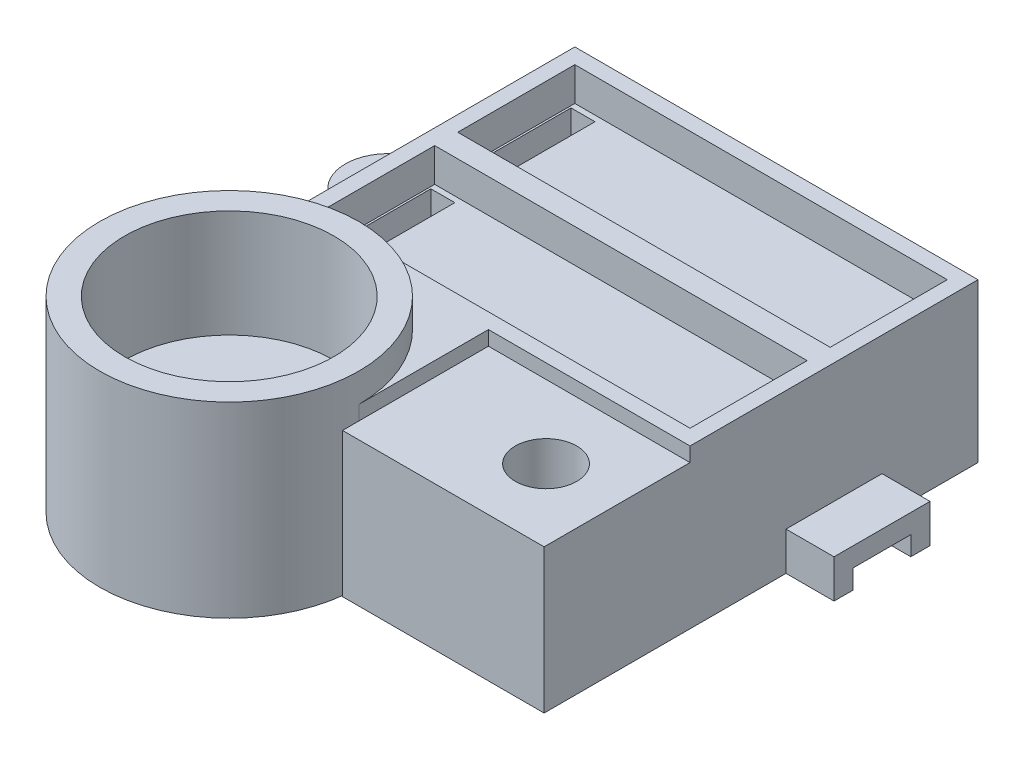
from build123d import *
from build123d.topology import SkipClean

# Parameters (mm, degrees)
SKETCH1_W            = 42
SKETCH1_H            = 30
BOSS_EXTRUDE1_DEPTH  = 10.5
SKETCH2_W            = 38.8
SKETCH2_H            = 12.2
CUT_EXTRUDE1_DEPTH   = 3.5
SKETCH3_W            = 2.5
SKETCH3_H            = 11
CUT_EXTRUDE2_DEPTH   = 2.6
SKETCH4_R            = 0.75
CUT_EXTRUDE3_DEPTH   = 52.973166153
SKETCH13_R           = 1.45
SKETCH13_W           = 1.6
SKETCH13_H           = 6.1
BOSS_EXTRUDE6_DEPTH  = 6
SKETCH15_R           = 4.45
SKETCH15_R_2         = 1.5
BOSS_EXTRUDE7_DEPTH  = 6
BOSS_EXTRUDE8_START  = 3
SKETCH16_R           = 1.5
BOSS_EXTRUDE8_DEPTH  = 3
SKETCH17_W           = 21
SKETCH17_H           = 10.5
BOSS_EXTRUDE9_DEPTH  = 21
BOSS_EXTRUDE20_DEPTH = 27
CUT_EXTRUDE15_DEPTH  = 27
SKETCH45_R           = 10.9
CUT_EXTRUDE16_DEPTH  = 8.2
CUT_EXTRUDE17_DEPTH  = 53.836445755
SKETCH48_W           = 3
SKETCH48_H           = 3
CUT_EXTRUDE18_DEPTH  = 15.1
SKETCH49_R           = 13.5
SKETCH49_R_2         = 10.9
BOSS_EXTRUDE21_DEPTH = 3
SKETCH51_W           = 28.827310349
SKETCH51_H           = 3
CUT_EXTRUDE20_DEPTH  = 54.350257731
SKETCH52_W           = 6
SKETCH52_H           = 2
CUT_EXTRUDE21_DEPTH  = 10
BOSS_EXTRUDE22_DEPTH = 5
SKETCH54_R           = 1.5
CUT_EXTRUDE22_DEPTH  = 3
SKETCH55_R           = 1.5
SKETCH55_R_2         = 1.45
BOSS_EXTRUDE23_DEPTH = 3
SKETCH57_W           = 21
SKETCH57_H           = 21
BOSS_EXTRUDE25_DEPTH = 3
SKETCH58_W           = 21
SKETCH58_H           = 5.8
CUT_EXTRUDE23_DEPTH  = 58.36941694
SKETCH59_R           = 3.2
CUT_EXTRUDE24_DEPTH  = 150
SKETCH60_W           = 21
SKETCH60_H           = 15.2
SKETCH60_R           = 3.2
BOSS_EXTRUDE26_DEPTH = 1.5
CUT_EXTRUDE25_DEPTH  = 3


with BuildPart() as part:
    # Sketch1 → Boss-Extrude1 (new body)
    with BuildSketch(Plane(origin=(0, 0, 0), x_dir=(1, 0, 0), z_dir=(0, 1, 0))):
        with Locations((21, 15)):
            Rectangle(SKETCH1_W, SKETCH1_H)
    extrude(amount=BOSS_EXTRUDE1_DEPTH)

    # Sketch2 → Cut-Extrude1 (cut)
    with BuildSketch(Plane(origin=(0, 10.5, 0), x_dir=(1, 0, 0), z_dir=(0, 1, 0))):
        with Locations((21, 22.3)):
            Rectangle(SKETCH2_W, SKETCH2_H)
        with Locations((21, 7.7)):
            Rectangle(SKETCH2_W, SKETCH2_H)
    extrude(amount=-CUT_EXTRUDE1_DEPTH, mode=Mode.SUBTRACT)

    # Sketch3 → Cut-Extrude2 (cut)
    with BuildSketch(Plane(origin=(0, 7, 0), x_dir=(1, 0, 0), z_dir=(0, 1, 0))):
        with Locations((3.05, 22.3)):
            Rectangle(SKETCH3_W, SKETCH3_H)
        with Locations((3.05, 7.7)):
            Rectangle(SKETCH3_W, SKETCH3_H)
    extrude(amount=-CUT_EXTRUDE2_DEPTH, mode=Mode.SUBTRACT)

    # Sketch4 → Cut-Extrude3 (cut, through all)
    with BuildSketch(Plane(origin=(0, 4.4, 0), x_dir=(1, 0, 0), z_dir=(0, 1, 0))):
        with Locations((3.05, 26.05)):
            Circle(SKETCH4_R)
        with BuildLine():
            ThreePointArc((3.8, 26.05), (3.05, 25.3), (2.3, 26.05))
            Line((2.3, 26.05), (2.3, 23.8))
            ThreePointArc((2.3, 23.8), (3.05, 24.55), (3.8, 23.8))
            Line((3.8, 23.8), (3.8, 26.05))
        make_face()
        with Locations((3.05, 23.8)):
            Circle(SKETCH4_R)
        with BuildLine():
            ThreePointArc((3.8, 23.8), (3.05, 23.05), (2.3, 23.8))
            Line((2.3, 23.8), (2.3, 20.8))
            ThreePointArc((2.3, 20.8), (3.05, 21.55), (3.8, 20.8))
            Line((3.8, 20.8), (3.8, 23.8))
        make_face()
        with Locations((3.05, 20.8)):
            Circle(SKETCH4_R)
        with BuildLine():
            ThreePointArc((3.8, 20.8), (3.05, 20.05), (2.3, 20.8))
            Line((2.3, 20.8), (2.3, 18.55))
            ThreePointArc((2.3, 18.55), (3.05, 19.3), (3.8, 18.55))
            Line((3.8, 18.55), (3.8, 20.8))
        make_face()
        with Locations((3.05, 18.55)):
            Circle(SKETCH4_R)
        with Locations((3.05, 11.45)):
            Circle(SKETCH4_R)
        with BuildLine():
            ThreePointArc((3.8, 11.45), (3.05, 10.7), (2.3, 11.45))
            Line((2.3, 11.45), (2.3, 9.2))
            ThreePointArc((2.3, 9.2), (3.05, 9.95), (3.8, 9.2))
            Line((3.8, 9.2), (3.8, 11.45))
        make_face()
        with Locations((3.05, 9.2)):
            Circle(SKETCH4_R)
        with BuildLine():
            ThreePointArc((3.8, 9.2), (3.05, 8.45), (2.3, 9.2))
            Line((2.3, 9.2), (2.3, 6.2))
            ThreePointArc((2.3, 6.2), (3.05, 6.95), (3.8, 6.2))
            Line((3.8, 6.2), (3.8, 9.2))
        make_face()
        with Locations((3.05, 6.2)):
            Circle(SKETCH4_R)
        with BuildLine():
            ThreePointArc((3.8, 6.2), (3.05, 5.45), (2.3, 6.2))
            Line((2.3, 6.2), (2.3, 3.95))
            ThreePointArc((2.3, 3.95), (3.05, 4.7), (3.8, 3.95))
            Line((3.8, 3.95), (3.8, 6.2))
        make_face()
        with Locations((3.05, 3.95)):
            Circle(SKETCH4_R)
    extrude(amount=-CUT_EXTRUDE3_DEPTH, mode=Mode.SUBTRACT)

    # Sketch13 → Boss-Extrude6 (add)
    # profile 1 of 12: a face of its own
    with BuildSketch(Plane.XZ):
        with BuildLine():
            Line((40.4, -28.4), (40.4, -22.132398502))
            ThreePointArc((40.4, -22.132398502), (39.065614287, -21.3660529), (37.55, -21.1))
            ThreePointArc((37.55, -21.1), (33.519801494, -23.663203774), (34.132398502, -28.4))
            Line((34.132398502, -28.4), (40.4, -28.4))
        make_face()
        with Locations(Location((37.55, -25.55, 0), (0, 0, 270))):
            Circle(SKETCH13_R, mode=Mode.SUBTRACT)
    # profile 2 of 12: a face of its own
    with BuildSketch(Plane.XZ):
        with BuildLine():
            ThreePointArc((37.55, -30), (40.696625176, -28.696625176), (42, -25.55))
            ThreePointArc((42, -25.55), (41.580198506, -23.663203774), (40.4, -22.132398502))
            Line((40.4, -22.132398502), (40.4, -28.4))
            Line((40.4, -28.4), (34.132398502, -28.4))
            ThreePointArc((34.132398502, -28.4), (35.663203774, -29.580198506), (37.55, -30))
        make_face()
    # profile 3 of 12: a face of its own
    with BuildSketch(Plane.XZ):
        with BuildLine():
            Line((42, -30), (42, -25.55))
            ThreePointArc((42, -25.55), (40.696625176, -28.696625176), (37.55, -30))
            Line((37.55, -30), (42, -30))
        make_face()
    # profile 4 of 12: a face of its own
    with BuildSketch(Plane.XZ):
        with BuildLine():
            Line((1.6, -15), (0, -15))
            Line((0, -15), (0, -30))
            Line((0, -30), (37.55, -30))
            ThreePointArc((37.55, -30), (35.663203774, -29.580198506), (34.132398502, -28.4))
            Line((34.132398502, -28.4), (1.6, -28.4))
            Line((1.6, -28.4), (1.6, -15))
        make_face()
    # profile 5 of 12: a face of its own
    with BuildSketch(Plane.XZ):
        with BuildLine():
            ThreePointArc((37.55, -8.9), (39.065614287, -8.6339471), (40.4, -7.867601498))
            Line((40.4, -7.867601498), (40.4, -1.6))
            Line((40.4, -1.6), (34.132398502, -1.6))
            ThreePointArc((34.132398502, -1.6), (33.519801494, -6.336796226), (37.55, -8.9))
        make_face()
        with Locations(Location((37.55, -4.45, 0), (0, 0, 270))):
            Circle(SKETCH13_R, mode=Mode.SUBTRACT)
    # profile 6 of 12: a face of its own
    with BuildSketch(Plane.XZ):
        with BuildLine():
            ThreePointArc((40.4, -7.867601498), (41.580198506, -6.336796226), (42, -4.45))
            ThreePointArc((42, -4.45), (40.696625172, -1.30337482), (37.549999989, 0))
            ThreePointArc((37.549999989, 0), (35.663203769, -0.419801496), (34.132398502, -1.6))
            Line((34.132398502, -1.6), (40.4, -1.6))
            Line((40.4, -1.6), (40.4, -7.867601498))
        make_face()
    # profile 7 of 12: a face of its own
    with BuildSketch(Plane.XZ):
        with BuildLine():
            Line((42, -4.45), (42, 0))
            Line((42, 0), (37.549999989, 0))
            ThreePointArc((37.549999989, 0), (40.696625172, -1.30337482), (42, -4.45))
        make_face()
    # profile 8 of 12: a face of its own
    with BuildSketch(Plane.XZ):
        with BuildLine():
            ThreePointArc((34.132398502, -1.6), (35.663203769, -0.419801496), (37.549999989, 0))
            Line((37.549999989, 0), (0, 0))
            Line((0, 0), (0, -15))
            Line((0, -15), (1.6, -15))
            Line((1.6, -15), (1.6, -1.6))
            Line((1.6, -1.6), (34.132398502, -1.6))
        make_face()
    # profile 9 of 12: a face of its own
    with BuildSketch(Plane.XZ):
        with BuildLine():
            Line((42, -8.9), (42, -4.45))
            ThreePointArc((42, -4.45), (41.580198506, -6.336796226), (40.4, -7.867601498))
            Line((40.4, -7.867601498), (40.4, -8.9))
            Line((40.4, -8.9), (42, -8.9))
        make_face()
    # profile 10 of 12: a face of its own
    with BuildSketch(Plane.XZ):
        with BuildLine():
            Line((42, -25.55), (42, -21.1))
            Line((42, -21.1), (40.4, -21.1))
            Line((40.4, -21.1), (40.4, -22.132398502))
            ThreePointArc((40.4, -22.132398502), (41.580198506, -23.663203774), (42, -25.55))
        make_face()
    # profile 11 of 12: a face of its own
    with BuildSketch(Plane.XZ):
        with Locations((41.2, -18.05)):
            Rectangle(SKETCH13_W, SKETCH13_H)
    # profile 12 of 12: a face of its own
    with BuildSketch(Plane.XZ):
        with Locations((41.2, -11.95)):
            Rectangle(SKETCH13_W, SKETCH13_H)
    extrude(amount=BOSS_EXTRUDE6_DEPTH)

    # Sketch15 → Boss-Extrude7 (add)
    # profile 1 of 3: a face of its own
    with BuildSketch(Plane.XZ):
        with Locations((-4.45, -15)):
            Circle(SKETCH15_R)
        with Locations(Location((-4.45, -15, 0), (0, 0, 270))):
            Circle(SKETCH15_R_2, mode=Mode.SUBTRACT)
    # profile 2 of 3: a face of its own
    with BuildSketch(Plane.XZ):
        with BuildLine():
            Line((0, -10.55), (-4.45, -10.55))
            ThreePointArc((-4.45, -10.55), (-1.303374824, -11.853374824), (0, -15))
            Line((0, -15), (0, -10.55))
        make_face()
    # profile 3 of 3: a face of its own
    with BuildSketch(Plane.XZ):
        with BuildLine():
            Line((0, -19.45), (0, -15))
            ThreePointArc((0, -15), (-1.303374824, -18.146625176), (-4.45, -19.45))
            Line((-4.45, -19.45), (0, -19.45))
        make_face()
    extrude(amount=BOSS_EXTRUDE7_DEPTH)

    # Sketch16 → Boss-Extrude8 (add)
    # profile 1 of 4: a face of its own
    with BuildSketch(Plane(origin=(0, 0, 0), x_dir=(1, 0, 0), z_dir=(0, 1, 0)).offset(BOSS_EXTRUDE8_START)):
        with BuildLine():
            Line((0, 19.45), (-4.45, 19.45))
            ThreePointArc((-4.45, 19.45), (-1.303374824, 18.146625176), (0, 15))
            Line((0, 15), (0, 19.45))
        make_face()
    # profile 2 of 4: a face of its own
    with BuildSketch(Plane(origin=(0, 0, 0), x_dir=(1, 0, 0), z_dir=(0, 1, 0)).offset(BOSS_EXTRUDE8_START)):
        with BuildLine():
            Line((0, 10.55), (0, 15))
            ThreePointArc((0, 15), (-1.303374824, 11.853374824), (-4.45, 10.55))
            Line((-4.45, 10.55), (0, 10.55))
        make_face()
    # profile 3 of 4: a face of its own
    with BuildSketch(Plane(origin=(0, 0, 0), x_dir=(1, 0, 0), z_dir=(0, 1, 0)).offset(BOSS_EXTRUDE8_START)):
        with BuildLine():
            ThreePointArc((0, 15), (-1.303374824, 18.146625176), (-4.45, 19.45))
            ThreePointArc((-4.45, 19.45), (-8.9, 15), (-4.45, 10.55))
            ThreePointArc((-4.45, 10.55), (-1.303374824, 11.853374824), (0, 15))
        make_face()
        with Locations(Location((-4.45, 15, 0), (0, 0, 90))):
            Circle(SKETCH16_R, mode=Mode.SUBTRACT)
    # profile 4 of 4: a face of its own
    with BuildSketch(Plane(origin=(0, 0, 0), x_dir=(1, 0, 0), z_dir=(0, 1, 0)).offset(BOSS_EXTRUDE8_START)):
        with Locations(Location((-4.45, 15, 0), (0, 0, 90))):
            Circle(SKETCH16_R)
    extrude(amount=-BOSS_EXTRUDE8_DEPTH)

    # Sketch43 → Boss-Extrude20 (add)
    with BuildSketch(Plane.XY):
        Polygon((21, 10.5), (21, -6), (21, -9), (-6, -9), (-6, -6), (-6, 10.5), align=None)
    extrude(amount=BOSS_EXTRUDE20_DEPTH)

    # Sketch44 → Cut-Extrude15 (cut)
    with BuildSketch(Plane(origin=(0, 10.5, 0), x_dir=(1, 0, 0), z_dir=(0, 1, 0))):
        with BuildLine():
            ThreePointArc((21, -13.5), (17.045941546, -23.045941546), (7.5, -27))
            Line((7.5, -27), (21, -27))
            Line((21, -27), (21, -13.5))
        make_face()
        with BuildLine():
            ThreePointArc((7.5, -27), (-2.045941546, -23.045941546), (-6, -13.5))
            Line((-6, -13.5), (-6, -27))
            Line((-6, -27), (7.5, -27))
        make_face()
        with BuildLine():
            Line((-6, 0), (-6, -13.5))
            ThreePointArc((-6, -13.5), (-4.4058809, -7.136038969), (0, -2.27502784))
            Line((0, -2.27502784), (0, 0))
            Line((0, 0), (-6, 0))
        make_face()
    extrude(amount=-CUT_EXTRUDE15_DEPTH, mode=Mode.SUBTRACT)

    # Sketch45 → Cut-Extrude16 (cut)
    with BuildSketch(Plane(origin=(0, 10.5, 0), x_dir=(1, 0, 0), z_dir=(0, 1, 0))):
        with Locations(Location((7.5, -13.5, 0), (0, 0, 270))):
            Circle(SKETCH45_R)
    extrude(amount=-CUT_EXTRUDE16_DEPTH, mode=Mode.SUBTRACT)

    # Sketch46 → Cut-Extrude17 (cut, through all)
    with BuildSketch(Plane(origin=(0, 2.3, 0), x_dir=(1, 0, 0), z_dir=(0, 1, 0))):
        with BuildLine():
            Line((6.85, -10.75), (6.85, -12.148149417))
            ThreePointArc((6.85, -12.148149417), (7.5, -12), (8.15, -12.148149417))
            Line((8.15, -12.148149417), (8.15, -10.75))
            Line((8.15, -10.75), (6.85, -10.75))
        make_face()
        with BuildLine():
            Line((6.85, -12.148149417), (6.85, -14.851850583))
            ThreePointArc((6.85, -14.851850583), (7.5, -15), (8.15, -14.851850583))
            Line((8.15, -14.851850583), (8.15, -12.148149417))
            ThreePointArc((8.15, -12.148149417), (7.5, -12), (6.85, -12.148149417))
        make_face()
        with BuildLine():
            Line((8.15, -12.148149417), (8.15, -14.851850583))
            ThreePointArc((8.15, -14.851850583), (8.76984251, -14.298435971), (9, -13.5))
            ThreePointArc((9, -13.5), (8.76984251, -12.701564029), (8.15, -12.148149417))
        make_face()
        with BuildLine():
            Line((6.85, -14.851850583), (6.85, -16.25))
            Line((6.85, -16.25), (8.15, -16.25))
            Line((8.15, -16.25), (8.15, -14.851850583))
            ThreePointArc((8.15, -14.851850583), (7.5, -15), (6.85, -14.851850583))
        make_face()
        with BuildLine():
            ThreePointArc((6.85, -12.148149417), (6, -13.5), (6.85, -14.851850583))
            Line((6.85, -14.851850583), (6.85, -12.148149417))
        make_face()
        with BuildLine():
            Line((15.7, -12.148149417), (15.7, -14.851850583))
            ThreePointArc((15.7, -14.851850583), (16.31984251, -14.298435971), (16.55, -13.5))
            ThreePointArc((16.55, -13.5), (16.31984251, -12.701564029), (15.7, -12.148149417))
        make_face()
        with BuildLine():
            ThreePointArc((14.4, -12.148149417), (13.55, -13.5), (14.4, -14.851850583))
            Line((14.4, -14.851850583), (14.4, -12.148149417))
        make_face()
        with BuildLine():
            ThreePointArc((14.4, -12.148149417), (15.05, -12), (15.7, -12.148149417))
            Line((15.7, -12.148149417), (15.7, -10.75))
            Line((15.7, -10.75), (14.4, -10.75))
            Line((14.4, -10.75), (14.4, -12.148149417))
        make_face()
        with BuildLine():
            Line((14.4, -16.25), (15.7, -16.25))
            Line((15.7, -16.25), (15.7, -14.851850583))
            ThreePointArc((15.7, -14.851850583), (15.05, -15), (14.4, -14.851850583))
            Line((14.4, -14.851850583), (14.4, -16.25))
        make_face()
    extrude(amount=-CUT_EXTRUDE17_DEPTH, mode=Mode.SUBTRACT)


with BuildPart() as body_2:
    # Sketch17 → Boss-Extrude9 (new body)
    with BuildSketch(Plane.XY):
        with Locations((31.5, 2.25)):
            Rectangle(SKETCH17_W, SKETCH17_H)
    extrude(amount=BOSS_EXTRUDE9_DEPTH)



with BuildPart() as cut_extrude17_kept_piece:
    # of the separate pieces the step leaves, the one the design keeps (cut_extrude17_pieces_kept)
    add(part.part.solids().sort_by_distance((21, -6, 0))[0])

    # Sketch48 → Cut-Extrude18 (cut)
    with BuildSketch(Plane(origin=(0, 0, -1.6), x_dir=(-1, 0, 0), z_dir=(0, 0, -1))):
        with Locations((-7.5, -4.5)):
            Rectangle(SKETCH48_W, SKETCH48_H)
        with Locations((-15.05, -4.5)):
            Rectangle(SKETCH48_W, SKETCH48_H)
    extrude(amount=-CUT_EXTRUDE18_DEPTH, mode=Mode.SUBTRACT)

    # Sketch49 → Boss-Extrude21 (add)
    with BuildSketch(Plane(origin=(0, 10.5, 0), x_dir=(1, 0, 0), z_dir=(0, 1, 0))):
        with Locations(Location((7.5, -13.5, 0), (0, 0, 270))):
            Circle(SKETCH49_R)
        with Locations(Location((7.5, -13.5, 0), (0, 0, 270))):
            Circle(SKETCH49_R_2, mode=Mode.SUBTRACT)
    extrude(amount=BOSS_EXTRUDE21_DEPTH)

    # Sketch51 → Cut-Extrude20 (cut, through all)
    with BuildSketch(Plane(origin=(0, 0, 0), x_dir=(-1, 0, 0), z_dir=(0, 0, -1))):
        with Locations((-6.586344825, -7.5)):
            Rectangle(SKETCH51_W, SKETCH51_H)
    extrude(amount=-CUT_EXTRUDE20_DEPTH, mode=Mode.SUBTRACT)

    # Sketch52 → Cut-Extrude21 (cut)
    with BuildSketch(Plane(origin=(42, 0, 0), x_dir=(0, 0, -1), z_dir=(1, 0, 0))):
        with Locations((15, -5)):
            Rectangle(SKETCH52_W, SKETCH52_H)
    extrude(amount=-CUT_EXTRUDE21_DEPTH, mode=Mode.SUBTRACT)

    # Sketch53 → Boss-Extrude22 (add)
    with BuildSketch(Plane(origin=(42, 0, 0), x_dir=(0, 0, -1), z_dir=(1, 0, 0))):
        Polygon((12, -6), (10, -6), (10, -2), (20, -2), (20, -6), (18, -6), (18, -4), (12, -4), align=None)
    extrude(amount=BOSS_EXTRUDE22_DEPTH)

    # Sketch54 → Cut-Extrude22 (cut)
    with BuildSketch(Plane.XZ.offset(6)):
        with Locations(Location((0, 13.5, 0), (0, 0, 270))):
            Circle(SKETCH54_R)
    extrude(amount=-CUT_EXTRUDE22_DEPTH, mode=Mode.SUBTRACT)

    # Sketch55 → Boss-Extrude23 (add, symmetric)
    with BuildSketch(Plane.XZ):
        with Locations(Location((-4.45, -15, 0), (0, 0, 270))):
            Circle(SKETCH55_R)
        with Locations(Location((37.55, -4.45, 0), (0, 0, 270))):
            Circle(SKETCH55_R_2)
        with Locations(Location((37.55, -25.55, 0), (0, 0, 270))):
            Circle(SKETCH55_R_2)
    extrude(amount=BOSS_EXTRUDE23_DEPTH, both=True)


with BuildPart() as body_2_1:
    add(body_2.part)

    add(cut_extrude17_kept_piece.part)  # Boss-Extrude25 merges Cut-Extrude17 kept piece
    # Sketch57 → Boss-Extrude25 (add)
    with BuildSketch(Plane.XZ.offset(3)):
        with Locations((31.5, 10.5)):
            Rectangle(SKETCH57_W, SKETCH57_H)
    extrude(amount=BOSS_EXTRUDE25_DEPTH)

    # Sketch58 → Cut-Extrude23 (cut, through all)
    with BuildSketch(Plane(origin=(0, 7.5, 0), x_dir=(1, 0, 0), z_dir=(0, 1, 0))):
        with Locations((31.5, -18.1)):
            Rectangle(SKETCH58_W, SKETCH58_H)
    extrude(amount=-CUT_EXTRUDE23_DEPTH, mode=Mode.SUBTRACT)

    # Sketch59 → Cut-Extrude24 (cut, symmetric)
    with BuildSketch(Plane(origin=(0, 7.5, 0), x_dir=(1, 0, 0), z_dir=(0, 1, 0))):
        with Locations(Location((34.6, -7.6, 0), (0, 0, 180))):
            Circle(SKETCH59_R)
    extrude(amount=CUT_EXTRUDE24_DEPTH, both=True, mode=Mode.SUBTRACT)

    # Sketch60 → Boss-Extrude26 (add)
    with SkipClean():  # the faces are left unmerged after this step: merging them gives an invalid solid
        with BuildSketch(Plane(origin=(0, 7.5, 0), x_dir=(1, 0, 0), z_dir=(0, 1, 0))):
            with Locations((31.5, -7.6)):
                Rectangle(SKETCH60_W, SKETCH60_H)
            with Locations((34.6, -7.6)):
                Circle(SKETCH60_R, mode=Mode.SUBTRACT)
        extrude(amount=BOSS_EXTRUDE26_DEPTH)

    # Sketch61 → Cut-Extrude25 (cut)
    with SkipClean():  # the faces are left unmerged after this step: merging them gives an invalid solid
        with BuildSketch(Plane.XZ):
            with BuildLine():
                Line((1.6, -28.4), (34.132398502, -28.4))
                ThreePointArc((34.132398502, -28.4), (34.403374824, -22.403374824), (40.4, -22.132398502))
                Line((40.4, -22.132398502), (40.4, -7.867601498))
                ThreePointArc((40.4, -7.867601498), (34.403374824, -7.596625176), (34.132398502, -1.6))
                Line((34.132398502, -1.6), (1.6, -1.6))
                Line((1.6, -1.6), (1.6, -28.4))
            make_face()
            with BuildLine():
                Line((3.8, -18.55), (3.8, -26.05))
                ThreePointArc((3.8, -26.05), (3.05, -26.8), (2.3, -26.05))
                Line((2.3, -26.05), (2.3, -18.55))
                ThreePointArc((2.3, -18.55), (3.05, -17.8), (3.8, -18.55))
            make_face(mode=Mode.SUBTRACT)
            with BuildLine():
                Line((3.8, -3.95), (3.8, -11.45))
                ThreePointArc((3.8, -11.45), (3.05, -12.2), (2.3, -11.45))
                Line((2.3, -11.45), (2.3, -3.95))
                ThreePointArc((2.3, -3.95), (3.05, -3.2), (3.8, -3.95))
            make_face(mode=Mode.SUBTRACT)
        extrude(amount=-CUT_EXTRUDE25_DEPTH, mode=Mode.SUBTRACT)


solid = body_2_1.part
